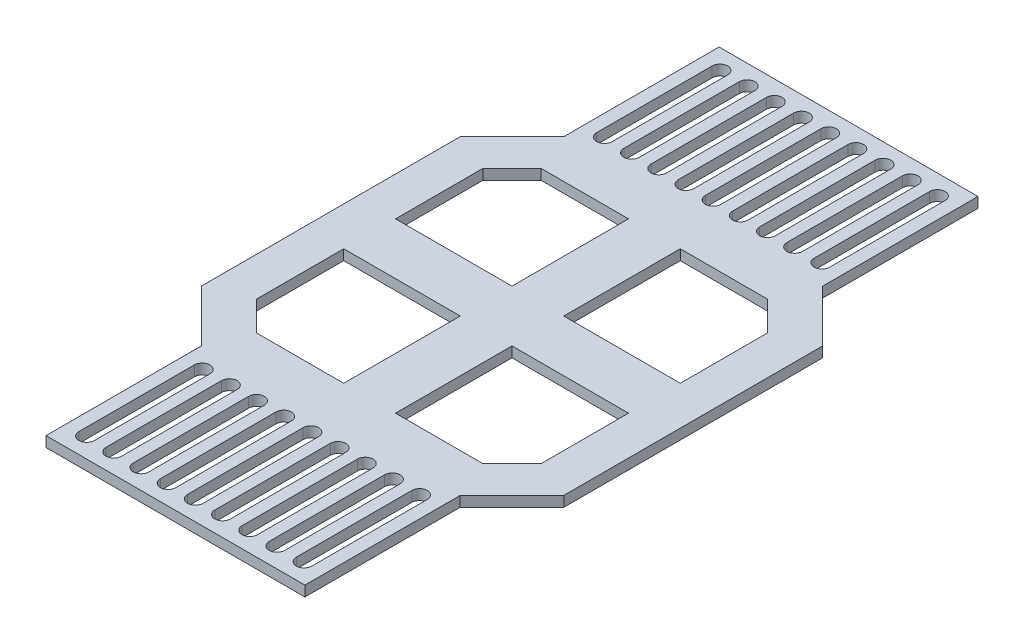
from build123d import *

# Parameters (mm, degrees)
BOSS_EXTRUDE1_DEPTH = 2
CUT_EXTRUDE1_DEPTH  = 2
CIRPATTERN1_COUNT   = 4


with BuildPart() as part:
    # Sketch2 → Boss-Extrude1 (new body)
    with BuildSketch(Plane(origin=(0, 0, 0), x_dir=(1, 0, 0), z_dir=(0, 1, 0))):
        Polygon((-35, 35), (-25, 35), (-25, 65), (25, 65), (25, 35), (35, 35), (35, -35), (25, -35), (25, -65), (-25, -65), (-25, -35), (-35, -35), align=None)
        with BuildLine():
            Line((-1.5, 38.847241674), (-1.5, 61.152758326))
            ThreePointArc((-1.5, 61.152758326), (0, 62.652758326), (1.5, 61.152758326))
            Line((1.5, 61.152758326), (1.5, 38.847241674))
            ThreePointArc((1.5, 38.847241674), (0, 37.347241674), (-1.5, 38.847241674))
        make_face(mode=Mode.SUBTRACT)
        with BuildLine():
            Line((3.75, 38.847241674), (3.75, 61.152758326))
            ThreePointArc((3.75, 61.152758326), (5.25, 62.652758326), (6.75, 61.152758326))
            Line((6.75, 61.152758326), (6.75, 38.847241674))
            ThreePointArc((6.75, 38.847241674), (5.25, 37.347241674), (3.75, 38.847241674))
        make_face(mode=Mode.SUBTRACT)
        with BuildLine():
            Line((9, 38.847241674), (9, 61.152758326))
            ThreePointArc((9, 61.152758326), (10.5, 62.652758326), (12, 61.152758326))
            Line((12, 61.152758326), (12, 38.847241674))
            ThreePointArc((12, 38.847241674), (10.5, 37.347241674), (9, 38.847241674))
        make_face(mode=Mode.SUBTRACT)
        with BuildLine():
            Line((14.25, 38.847241674), (14.25, 61.152758326))
            ThreePointArc((14.25, 61.152758326), (15.75, 62.652758326), (17.25, 61.152758326))
            Line((17.25, 61.152758326), (17.25, 38.847241674))
            ThreePointArc((17.25, 38.847241674), (15.75, 37.347241674), (14.25, 38.847241674))
        make_face(mode=Mode.SUBTRACT)
        with BuildLine():
            Line((19.5, 38.847241674), (19.5, 61.152758326))
            ThreePointArc((19.5, 61.152758326), (21, 62.652758326), (22.5, 61.152758326))
            Line((22.5, 61.152758326), (22.5, 38.847241674))
            ThreePointArc((22.5, 38.847241674), (21, 37.347241674), (19.5, 38.847241674))
        make_face(mode=Mode.SUBTRACT)
        with BuildLine():
            Line((-6.75, 38.847241674), (-6.75, 61.152758326))
            ThreePointArc((-6.75, 61.152758326), (-5.25, 62.652758326), (-3.75, 61.152758326))
            Line((-3.75, 61.152758326), (-3.75, 38.847241674))
            ThreePointArc((-3.75, 38.847241674), (-5.25, 37.347241674), (-6.75, 38.847241674))
        make_face(mode=Mode.SUBTRACT)
        with BuildLine():
            Line((-12, 38.847241674), (-12, 61.152758326))
            ThreePointArc((-12, 61.152758326), (-10.5, 62.652758326), (-9, 61.152758326))
            Line((-9, 61.152758326), (-9, 38.847241674))
            ThreePointArc((-9, 38.847241674), (-10.5, 37.347241674), (-12, 38.847241674))
        make_face(mode=Mode.SUBTRACT)
        with BuildLine():
            Line((-17.25, 38.847241674), (-17.25, 61.152758326))
            ThreePointArc((-17.25, 61.152758326), (-15.75, 62.652758326), (-14.25, 61.152758326))
            Line((-14.25, 61.152758326), (-14.25, 38.847241674))
            ThreePointArc((-14.25, 38.847241674), (-15.75, 37.347241674), (-17.25, 38.847241674))
        make_face(mode=Mode.SUBTRACT)
        with BuildLine():
            Line((-22.5, 38.847241674), (-22.5, 61.152758326))
            ThreePointArc((-22.5, 61.152758326), (-21, 62.652758326), (-19.5, 61.152758326))
            Line((-19.5, 61.152758326), (-19.5, 38.847241674))
            ThreePointArc((-19.5, 38.847241674), (-21, 37.347241674), (-22.5, 38.847241674))
        make_face(mode=Mode.SUBTRACT)
        with BuildLine():
            Line((3.75, -38.847241674), (3.75, -61.152758326))
            ThreePointArc((3.75, -61.152758326), (5.25, -62.652758326), (6.75, -61.152758326))
            Line((6.75, -61.152758326), (6.75, -38.847241674))
            ThreePointArc((6.75, -38.847241674), (5.25, -37.347241674), (3.75, -38.847241674))
        make_face(mode=Mode.SUBTRACT)
        with BuildLine():
            Line((-1.5, -38.847241674), (-1.5, -61.152758326))
            ThreePointArc((-1.5, -61.152758326), (0, -62.652758326), (1.5, -61.152758326))
            Line((1.5, -61.152758326), (1.5, -38.847241674))
            ThreePointArc((1.5, -38.847241674), (0, -37.347241674), (-1.5, -38.847241674))
        make_face(mode=Mode.SUBTRACT)
        with BuildLine():
            Line((9, -38.847241674), (9, -61.152758326))
            ThreePointArc((9, -61.152758326), (10.5, -62.652758326), (12, -61.152758326))
            Line((12, -61.152758326), (12, -38.847241674))
            ThreePointArc((12, -38.847241674), (10.5, -37.347241674), (9, -38.847241674))
        make_face(mode=Mode.SUBTRACT)
        with BuildLine():
            Line((14.25, -38.847241674), (14.25, -61.152758326))
            ThreePointArc((14.25, -61.152758326), (15.75, -62.652758326), (17.25, -61.152758326))
            Line((17.25, -61.152758326), (17.25, -38.847241674))
            ThreePointArc((17.25, -38.847241674), (15.75, -37.347241674), (14.25, -38.847241674))
        make_face(mode=Mode.SUBTRACT)
        with BuildLine():
            Line((19.5, -38.847241674), (19.5, -61.152758326))
            ThreePointArc((19.5, -61.152758326), (21, -62.652758326), (22.5, -61.152758326))
            Line((22.5, -61.152758326), (22.5, -38.847241674))
            ThreePointArc((22.5, -38.847241674), (21, -37.347241674), (19.5, -38.847241674))
        make_face(mode=Mode.SUBTRACT)
        with BuildLine():
            Line((-6.75, -38.847241674), (-6.75, -61.152758326))
            ThreePointArc((-6.75, -61.152758326), (-5.25, -62.652758326), (-3.75, -61.152758326))
            Line((-3.75, -61.152758326), (-3.75, -38.847241674))
            ThreePointArc((-3.75, -38.847241674), (-5.25, -37.347241674), (-6.75, -38.847241674))
        make_face(mode=Mode.SUBTRACT)
        with BuildLine():
            Line((-12, -38.847241674), (-12, -61.152758326))
            ThreePointArc((-12, -61.152758326), (-10.5, -62.652758326), (-9, -61.152758326))
            Line((-9, -61.152758326), (-9, -38.847241674))
            ThreePointArc((-9, -38.847241674), (-10.5, -37.347241674), (-12, -38.847241674))
        make_face(mode=Mode.SUBTRACT)
        with BuildLine():
            Line((-17.25, -38.847241674), (-17.25, -61.152758326))
            ThreePointArc((-17.25, -61.152758326), (-15.75, -62.652758326), (-14.25, -61.152758326))
            Line((-14.25, -61.152758326), (-14.25, -38.847241674))
            ThreePointArc((-14.25, -38.847241674), (-15.75, -37.347241674), (-17.25, -38.847241674))
        make_face(mode=Mode.SUBTRACT)
        with BuildLine():
            Line((-22.5, -38.847241674), (-22.5, -61.152758326))
            ThreePointArc((-22.5, -61.152758326), (-21, -62.652758326), (-19.5, -61.152758326))
            Line((-19.5, -61.152758326), (-19.5, -38.847241674))
            ThreePointArc((-19.5, -38.847241674), (-21, -37.347241674), (-22.5, -38.847241674))
        make_face(mode=Mode.SUBTRACT)
    extrude(amount=BOSS_EXTRUDE1_DEPTH)

    # Sketch4 → Cut-Extrude1 (cut)
    with BuildSketch(Plane.XZ):
        Polygon((25, 35), (35, 25), (35, 35), align=None)
        Polygon((21.893398282, 27.5), (27.5, 21.893398282), (27.5, 5), (5, 5), (5, 27.5), align=None)
    cut_extrude1 = extrude(amount=-CUT_EXTRUDE1_DEPTH, mode=Mode.SUBTRACT)

    # CirPattern1: Cut-Extrude1 ×4 about axis
    cirpattern1_axis = Axis((0, 0, 0), (0, 1, 0))
    for i in range(1, CIRPATTERN1_COUNT):
        add(cut_extrude1.rotate(cirpattern1_axis, i * 360 / CIRPATTERN1_COUNT), mode=Mode.SUBTRACT)


solid = part.part
